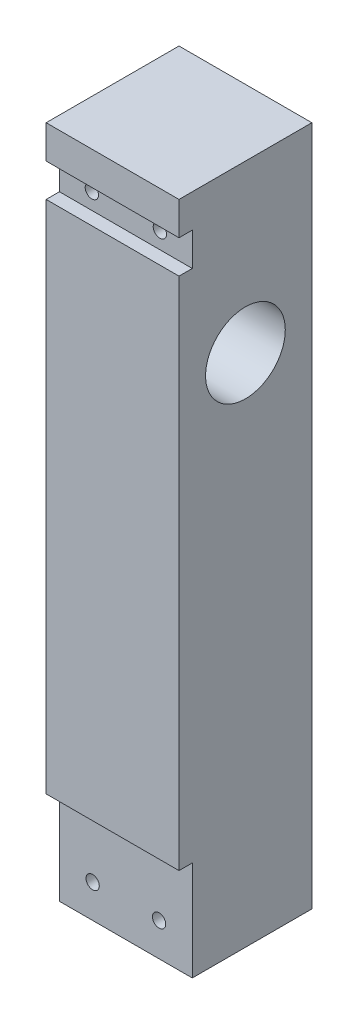
from build123d import *

# Parameters (mm, degrees)
SKETCH1_W           = 20
SKETCH1_H           = 120
SKETCH1_R           = 2.5
BOSS_EXTRUDE2_DEPTH = 20
SKETCH10_R          = 6
CUT_EXTRUDE1_DEPTH  = 21
SKETCH11_R          = 1
CUT_EXTRUDE2_DEPTH  = 21
SKETCH12_R          = 2
CUT_EXTRUDE3_DEPTH  = 5
SKETCH13_R          = 1
CUT_EXTRUDE4_DEPTH  = 21
SKETCH14_R          = 2
CUT_EXTRUDE5_DEPTH  = 5
SKETCH16_W          = 20
SKETCH16_H          = 5
SKETCH16_H_2        = 20
CUT_EXTRUDE6_DEPTH  = 2
SKETCH17_W          = 18
SKETCH17_H          = 5
CUT_EXTRUDE7_DEPTH  = 21
SKETCH18_W          = 20
SKETCH18_H          = 12.5
CUT_EXTRUDE8_DEPTH  = 21


with BuildPart() as part:
    # Sketch1 → Boss-Extrude2 (new body)
    with BuildSketch(Plane(origin=(0, 0, 0), x_dir=(0, 0, -1), z_dir=(1, 0, 0))):
        with Locations((10, 60)):
            Rectangle(SKETCH1_W, SKETCH1_H)
        with Locations((10, 82.5)):
            Circle(SKETCH1_R, mode=Mode.SUBTRACT)
    extrude(amount=-BOSS_EXTRUDE2_DEPTH)

    # Sketch10 → Cut-Extrude1 (cut, through all)
    with BuildSketch(Plane(origin=(0, 0, 0), x_dir=(0, 0, -1), z_dir=(1, 0, 0))):
        with Locations((10, 82.5)):
            Circle(SKETCH10_R)
    extrude(amount=-CUT_EXTRUDE1_DEPTH, mode=Mode.SUBTRACT)

    # Sketch11 → Cut-Extrude2 (cut, through all)
    with BuildSketch(Plane.XY):
        with Locations((-15, 10)):
            Circle(SKETCH11_R)
        with Locations((-5, 10)):
            Circle(SKETCH11_R)
    extrude(amount=-CUT_EXTRUDE2_DEPTH, mode=Mode.SUBTRACT)

    # Sketch12 → Cut-Extrude3 (cut)
    with BuildSketch(Plane(origin=(0, 0, -20), x_dir=(-1, 0, 0), z_dir=(0, 0, -1))):
        with Locations((5, 10)):
            Circle(SKETCH12_R)
        with Locations((15, 10)):
            Circle(SKETCH12_R)
    extrude(amount=-CUT_EXTRUDE3_DEPTH, mode=Mode.SUBTRACT)

    # Sketch13 → Cut-Extrude4 (cut, through all)
    with BuildSketch(Plane(origin=(0, 0, -20), x_dir=(-1, 0, 0), z_dir=(0, 0, -1))):
        with Locations((4.880538742, 100)):
            Circle(SKETCH13_R)
        with Locations((15.119461258, 100)):
            Circle(SKETCH13_R)
    extrude(amount=-CUT_EXTRUDE4_DEPTH, mode=Mode.SUBTRACT)

    # Sketch14 → Cut-Extrude5 (cut)
    with BuildSketch(Plane(origin=(0, 0, -20), x_dir=(-1, 0, 0), z_dir=(0, 0, -1))):
        with Locations((4.880538742, 100)):
            Circle(SKETCH14_R)
        with Locations((15.119461258, 100)):
            Circle(SKETCH14_R)
    extrude(amount=-CUT_EXTRUDE5_DEPTH, mode=Mode.SUBTRACT)

    # Sketch16 → Cut-Extrude6 (cut)
    with BuildSketch(Plane.XY):
        with Locations((-10, 100)):
            Rectangle(SKETCH16_W, SKETCH16_H)
        with Locations((-10, 10)):
            Rectangle(SKETCH16_W, SKETCH16_H_2)
    extrude(amount=-CUT_EXTRUDE6_DEPTH, mode=Mode.SUBTRACT)

    # Sketch17 → Cut-Extrude7 (cut, through all)
    with BuildSketch(Plane.ZY.offset(20)):
        with Locations((-11, 2.5)):
            Rectangle(SKETCH17_W, SKETCH17_H)
    extrude(amount=-CUT_EXTRUDE7_DEPTH, mode=Mode.SUBTRACT)

    # Sketch18 → Cut-Extrude8 (cut, through all)
    with BuildSketch(Plane.XY):
        with Locations((-10, 113.75)):
            Rectangle(SKETCH18_W, SKETCH18_H)
    extrude(amount=-CUT_EXTRUDE8_DEPTH, mode=Mode.SUBTRACT)


solid = part.part
